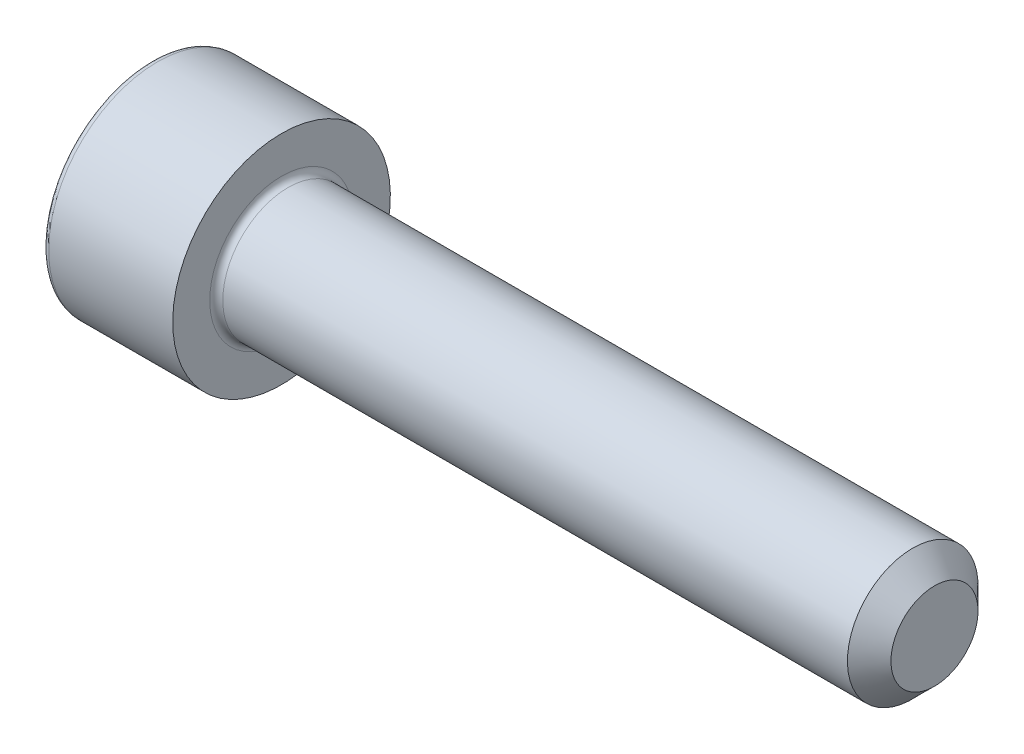
from build123d import *

# Parameters (mm, degrees)
CUT_EXTRUDE_1_DEPTH = 2.5
FILLET_1_R          = 0.3
CHAMFER_1_SIZE      = 1


with BuildPart() as part:
    # Эскиз1 → Повернуть1 (revolve)
    with BuildSketch(Plane.XY):
        Polygon((0, 0), (0, 5), (6, 5), (6, 3), (36, 3), (36, 0), align=None)
    revolve(axis=Axis((36, 0, 0), (-1, 0, 0)))

    # Эскиз2 → Вырез-Вытянуть1 (cut)
    with BuildSketch(Plane.ZY):
        Polygon((-1.443375673, 2.5), (-2.886751346, 0), (-1.443375673, -2.5), (1.443375673, -2.5), (2.886751346, 0), (1.443375673, 2.5), align=None)
    extrude(amount=-CUT_EXTRUDE_1_DEPTH, mode=Mode.SUBTRACT)

    # Скругление1
    fillet_1_edges = [part.edges().sort_by_distance(p)[0] for p in [
        (6, -3, 0),
        (0, -5, 0),
    ]]
    fillet(fillet_1_edges, radius=FILLET_1_R)

    # Фаска1
    chamfer_1_edges = [part.edges().sort_by_distance(p)[0] for p in [
        (36, -3, 0),
    ]]
    chamfer(chamfer_1_edges, length=CHAMFER_1_SIZE)


solid = part.part
